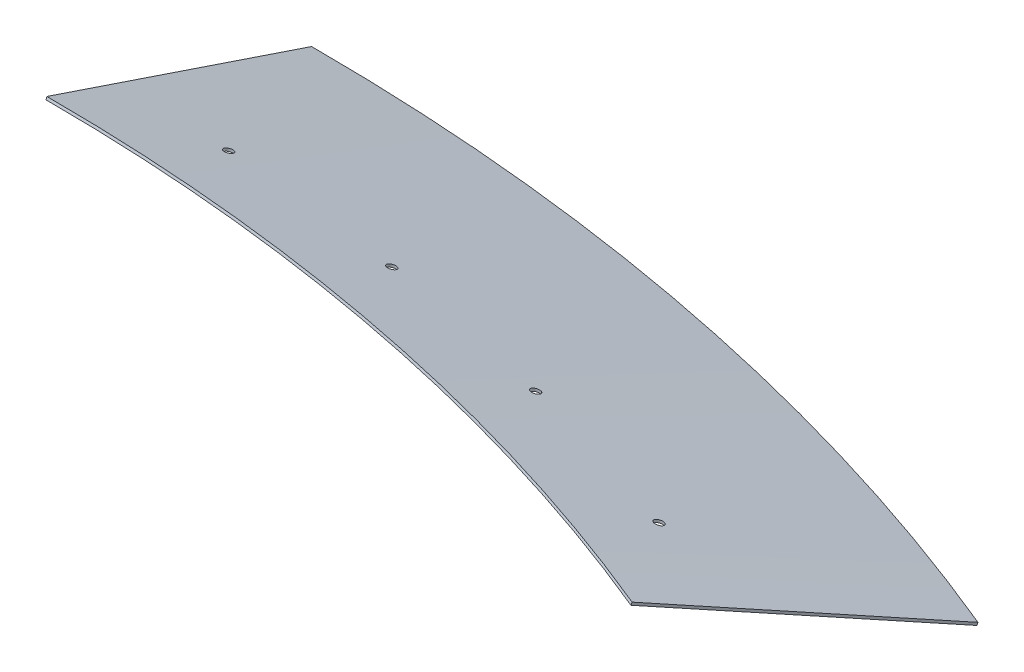
from build123d import *

# Parameters (mm, degrees)
REVOLVE1_ANGLE     = 22.5
CUT_EXTRUDE1_REACH = 105.843
SKETCH10_R         = 5


with BuildPart() as part:
    # Sketch8 → Revolve1 (revolve)
    with BuildSketch(Plane(origin=(0, 0, 0), x_dir=(0, 0, -1), z_dir=(1, 0, 0))):
        Polygon((2162, 101), (2462, 0), (2462.957208619, 2.843193919), (2162.957208619, 103.843193919), align=None)
    revolve(axis=Axis((0, 453.48709258, 0), (0, -1, 0)), revolution_arc=REVOLVE1_ANGLE)

    # Sketch10 → Cut-Extrude1 (cut, up to next)
    with BuildSketch(Plane(origin=(0, 0, 0), x_dir=(1, 0, 0), z_dir=(0, 1, 0)), mode=Mode.PRIVATE) as cut_extrude1_sk1:
        with Locations((129.148495614, 2239.842320533)):
            Circle(SKETCH10_R)
    cut_extrude1_tool1 = extrude(cut_extrude1_sk1.sketch, amount=CUT_EXTRUDE1_REACH, mode=Mode.PRIVATE) & part.part
    add(cut_extrude1_tool1.solids().sort_by_distance((129.148496, 0, -2239.842321))[0], mode=Mode.SUBTRACT)
    # Sketch10 → Cut-Extrude1 (cut, up to next)
    with BuildSketch(Plane(origin=(0, 0, 0), x_dir=(1, 0, 0), z_dir=(0, 1, 0)), mode=Mode.PRIVATE) as cut_extrude1_sk2:
        with Locations((335.491897752, 2218.336796186)):
            Circle(SKETCH10_R)
    cut_extrude1_tool2 = extrude(cut_extrude1_sk2.sketch, amount=CUT_EXTRUDE1_REACH, mode=Mode.PRIVATE) & part.part
    add(cut_extrude1_tool2.solids().sort_by_distance((335.491898, 0, -2218.336796))[0], mode=Mode.SUBTRACT)
    # Sketch10 → Cut-Extrude1 (cut, up to next)
    with BuildSketch(Plane(origin=(0, 0, 0), x_dir=(1, 0, 0), z_dir=(0, 1, 0)), mode=Mode.PRIVATE) as cut_extrude1_sk3:
        with Locations((538.96664165, 2177.863153175)):
            Circle(SKETCH10_R)
    cut_extrude1_tool3 = extrude(cut_extrude1_sk3.sketch, amount=CUT_EXTRUDE1_REACH, mode=Mode.PRIVATE) & part.part
    add(cut_extrude1_tool3.solids().sort_by_distance((538.966642, 0, -2177.863153))[0], mode=Mode.SUBTRACT)
    # Sketch10 → Cut-Extrude1 (cut, up to next)
    with BuildSketch(Plane(origin=(0, 0, 0), x_dir=(1, 0, 0), z_dir=(0, 1, 0)), mode=Mode.PRIVATE) as cut_extrude1_sk4:
        with Locations((737.832895426, 2118.767465579)):
            Circle(SKETCH10_R)
    cut_extrude1_tool4 = extrude(cut_extrude1_sk4.sketch, amount=CUT_EXTRUDE1_REACH, mode=Mode.PRIVATE) & part.part
    add(cut_extrude1_tool4.solids().sort_by_distance((737.832895, 0, -2118.767466))[0], mode=Mode.SUBTRACT)


solid = part.part
